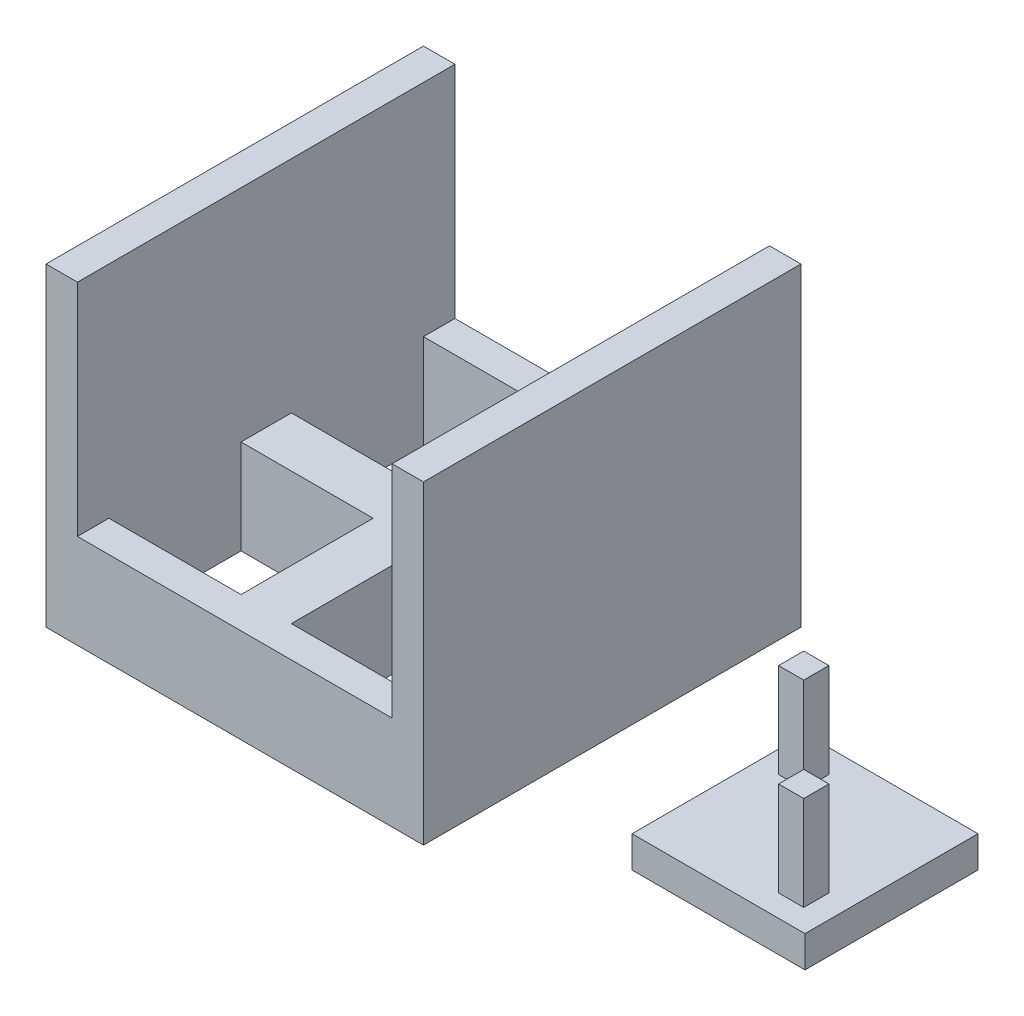
from build123d import *

# Parameters (mm, degrees)
SKETCH1_W               = 60
SKETCH1_H               = 60
BOSS_EXTRUDE1_DEPTH     = 50
SKETCH2_W               = 50
SKETCH2_H               = 50
CUT_EXTRUDE1_DEPTH      = 50
SKETCH3_W               = 8
SKETCH3_H               = 56.785207986
BOSS_EXTRUDE2_DEPTH     = 50
SKETCH5_W               = 56.41599337
SKETCH5_H               = 8
BOSS_EXTRUDE3_DEPTH     = 50
SKETCH6_W               = 50
SKETCH6_H               = 35
CUT_EXTRUDE2_DEPTH      = 30
CUT_EXTRUDE2_DEPTH_BACK = 30
SKETCH7_W               = 27.5
SKETCH7_H               = 27.5
BOSS_EXTRUDE4_DEPTH     = 5
SKETCH9_W               = 4
SKETCH9_H               = 4
BOSS_EXTRUDE5_DEPTH     = 20
SKETCH10_W              = 4
SKETCH10_H              = 4
BOSS_EXTRUDE6_DEPTH     = 20


with BuildPart() as part:
    # Sketch1 → Boss-Extrude1 (new body)
    with BuildSketch(Plane(origin=(0, 0, 0), x_dir=(1, 0, 0), z_dir=(0, 1, 0))):
        Rectangle(SKETCH1_W, SKETCH1_H)
    extrude(amount=BOSS_EXTRUDE1_DEPTH)

    # Sketch2 → Cut-Extrude1 (cut)
    with BuildSketch(Plane(origin=(0, 0, 0), x_dir=(1, 0, 0), z_dir=(0, 1, 0))):
        Rectangle(SKETCH2_W, SKETCH2_H)
    extrude(amount=CUT_EXTRUDE1_DEPTH, mode=Mode.SUBTRACT)

    # Sketch3 → Boss-Extrude2 (add)
    with BuildSketch(Plane(origin=(0, 0, 0), x_dir=(1, 0, 0), z_dir=(0, 1, 0))):
        Rectangle(SKETCH3_W, SKETCH3_H)
    extrude(amount=BOSS_EXTRUDE2_DEPTH)

    # Sketch5 → Boss-Extrude3 (add)
    with BuildSketch(Plane(origin=(0, 0, 0), x_dir=(1, 0, 0), z_dir=(0, 1, 0))):
        Rectangle(SKETCH5_W, SKETCH5_H)
    extrude(amount=BOSS_EXTRUDE3_DEPTH)

    # Sketch6 → Cut-Extrude2 (cut, two sides)
    with BuildSketch(Plane.XY) as cut_extrude2_sk:
        with Locations((0, 32.5)):
            Rectangle(SKETCH6_W, SKETCH6_H)
    extrude(amount=CUT_EXTRUDE2_DEPTH, mode=Mode.SUBTRACT)
    extrude(cut_extrude2_sk.sketch, amount=-CUT_EXTRUDE2_DEPTH_BACK, mode=Mode.SUBTRACT)


with BuildPart() as body_2:
    # Sketch7 → Boss-Extrude4 (new body)
    with BuildSketch(Plane(origin=(0, 0, 0), x_dir=(1, 0, 0), z_dir=(0, 1, 0))):
        with Locations((63.75, -3.104551975)):
            Rectangle(SKETCH7_W, SKETCH7_H)
    extrude(amount=BOSS_EXTRUDE4_DEPTH)

    # Sketch9 → Boss-Extrude5 (add)
    with BuildSketch(Plane(origin=(0, 0, 0), x_dir=(1, 0, 0), z_dir=(0, 1, 0))):
        with Locations((55.5, 4.945448025)):
            Rectangle(SKETCH9_W, SKETCH9_H)
    extrude(amount=BOSS_EXTRUDE5_DEPTH)

    # Sketch10 → Boss-Extrude6 (add)
    with BuildSketch(Plane(origin=(0, 0, 0), x_dir=(1, 0, 0), z_dir=(0, 1, 0))):
        with Locations((71.8, -11.354551975)):
            Rectangle(SKETCH10_W, SKETCH10_H)
    extrude(amount=BOSS_EXTRUDE6_DEPTH)


solid = Compound([part.part, body_2.part])
